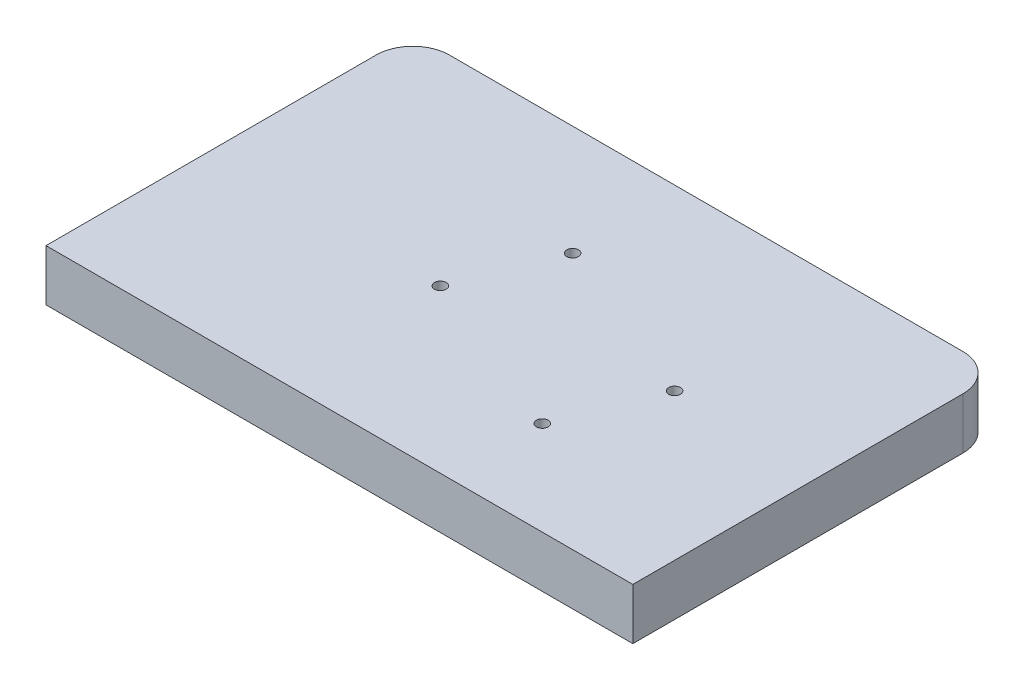
from build123d import *

# Parameters (mm, degrees)
SKETCH2_W           = 203.2
SKETCH2_H           = 127
BOSS_EXTRUDE2_DEPTH = 17.78
FILLET1_R           = 12.7
SKETCH5_R           = 2.0828
CUT_EXTRUDE2_DEPTH  = 12.7
SKETCH6_R           = 2.032
CUT_EXTRUDE3_DEPTH  = 12.7


with BuildPart() as part:
    # Sketch2 → Boss-Extrude2 (new body)
    with BuildSketch(Plane(origin=(0, 0, 0), x_dir=(1, 0, 0), z_dir=(0, 1, 0))):
        Rectangle(SKETCH2_W, SKETCH2_H)
    extrude(amount=BOSS_EXTRUDE2_DEPTH)

    # Fillet1
    fillet1_edges = [part.edges().sort_by_distance(p)[0] for p in [
        (-101.6, 8.89, -63.5),
        (101.6, 8.89, -63.5),
    ]]
    fillet(fillet1_edges, radius=FILLET1_R)

    # Sketch5 → Cut-Extrude2 (cut)
    with BuildSketch(Plane.XZ):
        with Locations((50.8, 49.8348)):
            Circle(SKETCH5_R)
        with Locations((33.5788, 25.0698)):
            Circle(SKETCH5_R)
        with Locations((-50.8, 25.0698)):
            Circle(SKETCH5_R)
        with Locations((-33.5788, 49.8348)):
            Circle(SKETCH5_R)
    extrude(amount=-CUT_EXTRUDE2_DEPTH, mode=Mode.SUBTRACT)

    # Sketch6 → Cut-Extrude3 (cut)
    with BuildSketch(Plane(origin=(0, 17.78, 0), x_dir=(1, 0, 0), z_dir=(0, 1, 0))):
        with Locations((-8.13412282, 25.4)):
            Circle(SKETCH6_R)
        with Locations((50.8, 1.756413821)):
            Circle(SKETCH6_R)
        with Locations((-21.251584432, -7.296651341)):
            Circle(SKETCH6_R)
        with Locations((37.682538388, -30.94023752)):
            Circle(SKETCH6_R)
    extrude(amount=-CUT_EXTRUDE3_DEPTH, mode=Mode.SUBTRACT)


solid = part.part
